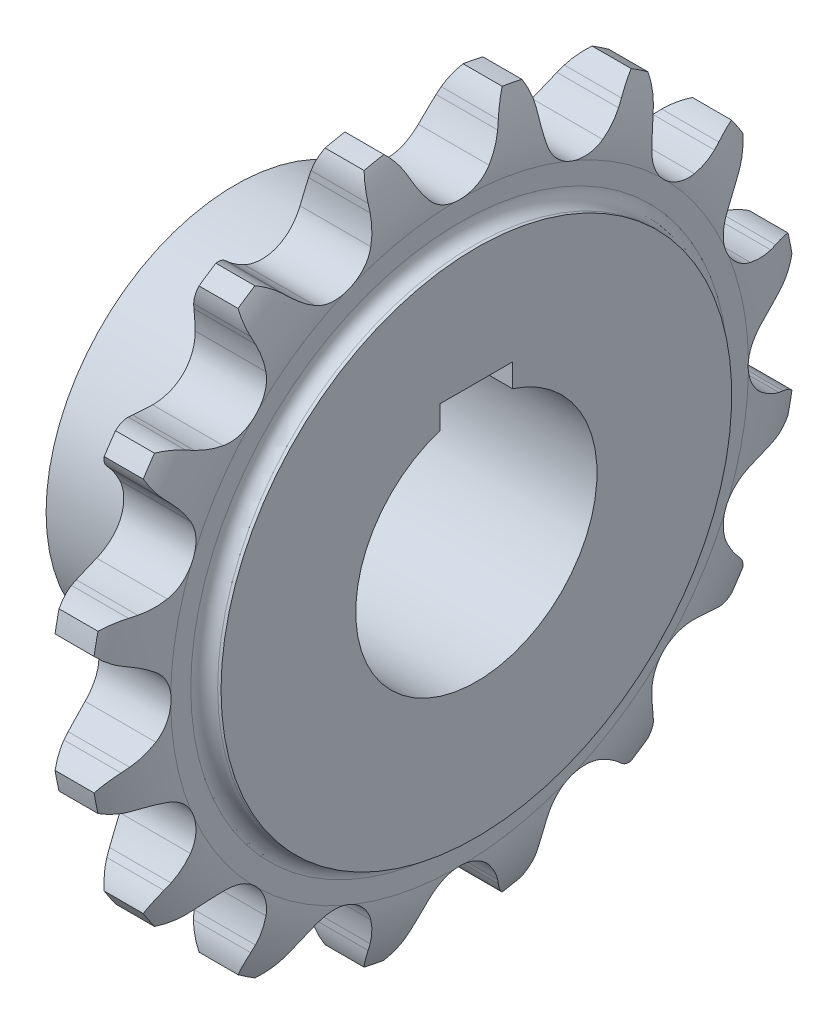
from build123d import *

# Parameters (mm, degrees)
EXTRUDECUTONE_DEPTH     = 13.151282733
PATTERNONE_COUNT        = 16
CUT_EXTRUDEB_DEPTH      = 124.406757142
CUT_EXTRUDEB_DEPTH_BACK = 124.406757142
SKETCHKEY_W             = 18
SKETCHKEY_H             = 19.400000095
CUT_EXTRUDE_3_REACH     = 127.491
SKETCH_3_R              = 30
SKETCH_4_R              = 47
EXTRUDE_1_DEPTH         = 33.7
FILLET_1_R              = 5


with BuildPart() as part:
    # Sketch1 → Revolve 2 (revolve)
    with BuildSketch(Plane.XY):
        with BuildLine():
            Line((-13.151282733, 0), (-13.151282733, 63.5))
            Line((-13.151282733, 63.5), (-12.316526186, 63.5))
            ThreePointArc((-12.316526186, 63.5), (-9.955478127, 64.477978127), (-8.9775, 66.839026186))
            Line((-8.9775, 66.839026186), (-8.9775, 71.847565466))
            ThreePointArc((-8.9775, 71.847565466), (-7.99285275, 80.199530429), (-4.85, 88))
            Line((-4.85, 88), (4.85, 88))
            ThreePointArc((4.85, 88), (7.99285275, 80.199530429), (8.9775, 71.847565466))
            Line((8.9775, 71.847565466), (8.9775, 66.839026186))
            ThreePointArc((8.9775, 66.839026186), (9.955478127, 64.477978127), (12.316526186, 63.5))
            Line((12.316526186, 63.5), (13.151282733, 63.5))
            Line((13.151282733, 63.5), (13.151282733, 0))
            Line((13.151282733, 0), (-13.151282733, 0))
        make_face()
    revolve(axis=Axis((-4, 0, 0), (1, 0, 0)))

    # Sketch2 → ExtrudeCutOne (cut, symmetric)
    with BuildSketch(Plane(origin=(0, 0, 0), x_dir=(0, 0, -1), z_dir=(1, 0, 0))):
        with BuildLine():
            Line((10.783358256, 80.700090369), (11.504219786, 82.300343625))
            ThreePointArc((11.504219786, 82.300343625), (12.877809039, 84.690018615), (14.692320511, 86.76482996))
            ThreePointArc((14.692320511, 86.76482996), (0, 88), (-14.692320511, 86.76482996))
            ThreePointArc((-14.692320511, 86.76482996), (-12.877809039, 84.690018615), (-11.504219786, 82.300343625))
            Line((-11.504219786, 82.300343625), (-10.783358256, 80.700090369))
            ThreePointArc((-10.783358256, 80.700090369), (-9.313433144, 77.920953304), (-7.504535924, 75.349538614))
            ThreePointArc((-7.504535924, 75.349538614), (0, 71.749940466), (7.504535924, 75.349538614))
            ThreePointArc((7.504535924, 75.349538614), (9.313433144, 77.920953304), (10.783358256, 80.700090369))
        make_face()
    extrudecutone = extrude(amount=EXTRUDECUTONE_DEPTH, both=True, mode=Mode.SUBTRACT)

    # PatternOne: ExtrudeCutOne ×16 about axis
    patternone_axis = Axis((-4, 0, 0), (1, 0, 0))
    for i in range(1, PATTERNONE_COUNT):
        add(extrudecutone.rotate(patternone_axis, i * 360 / PATTERNONE_COUNT), mode=Mode.SUBTRACT)

    # SketchKey → Cut-ExtrudeB (cut, two sides: drawn at the far end of the back side and taken through both)
    with BuildSketch(Plane(origin=(0, 0, 0), x_dir=(0, 0, -1), z_dir=(1, 0, 0)).offset(-CUT_EXTRUDEB_DEPTH_BACK)):
        with Locations((0, 24.700000048)):
            Rectangle(SKETCHKEY_W, SKETCHKEY_H)
    extrude(amount=CUT_EXTRUDEB_DEPTH + CUT_EXTRUDEB_DEPTH_BACK, mode=Mode.SUBTRACT)

    # 草图3 → 切除-拉伸3 (cut, up to next)
    with BuildSketch(Plane(origin=(13.151282733, 0, 0), x_dir=(0, 0, -1), z_dir=(1, 0, 0)), mode=Mode.PRIVATE) as cut_extrude_3_sk1:
        Circle(SKETCH_3_R)
    cut_extrude_3_tool1 = extrude(cut_extrude_3_sk1.sketch, amount=-CUT_EXTRUDE_3_REACH, mode=Mode.PRIVATE) & part.part
    add(cut_extrude_3_tool1.solids().sort_by_distance((13.151283, 0, 0))[0], mode=Mode.SUBTRACT)

    # 草图4 → 凸台-拉伸1 (add)
    with BuildSketch(Plane.ZY.offset(13.151282733)):
        Circle(SKETCH_4_R)
        with BuildLine():
            Line((9, 34.400000095), (9, 28.618176043))
            ThreePointArc((9, 28.618176043), (0, -30), (-9, 28.618176043))
            Line((-9, 28.618176043), (-9, 34.400000095))
            Line((-9, 34.400000095), (9, 34.400000095))
        make_face(mode=Mode.SUBTRACT)
    extrude(amount=EXTRUDE_1_DEPTH)

    # 圆角1
    fillet_1_edges = [part.edges().sort_by_distance(p)[0] for p in [
        (-13.151282733, 0, -47),
    ]]
    fillet(fillet_1_edges, radius=FILLET_1_R)


solid = part.part
